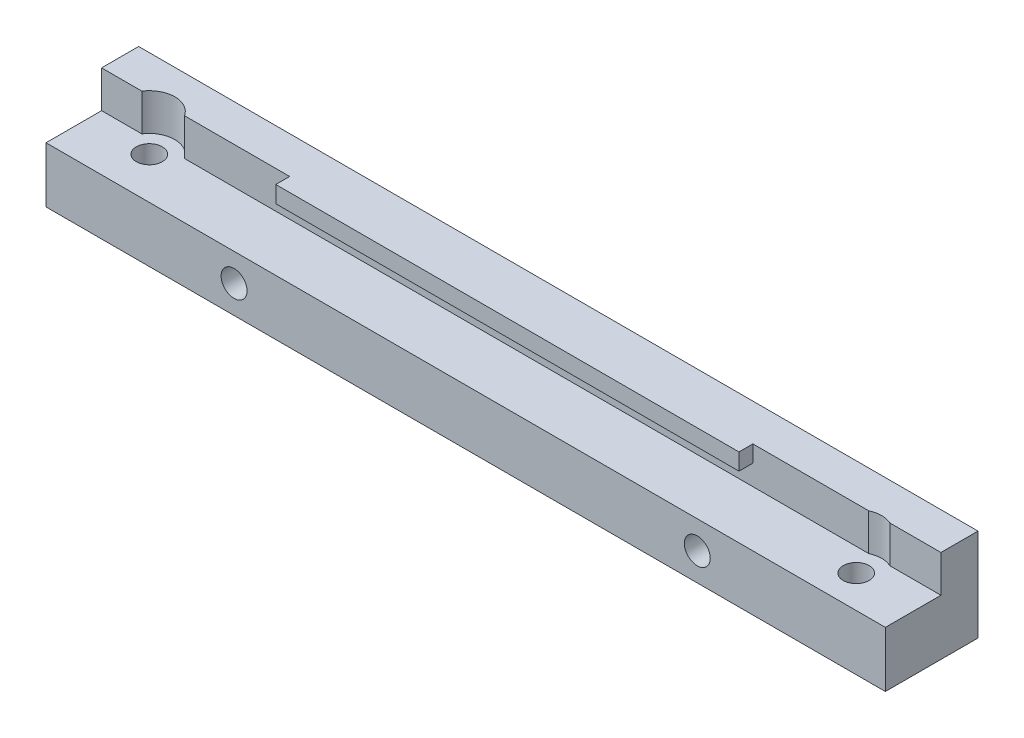
from build123d import *

# Parameters (mm, degrees)
ESQUISSE1_W             = 90.6
ESQUISSE1_H             = 10
BOSS_EXTRU_1_DEPTH      = 10
ESQUISSE2_W             = 90.6
ESQUISSE2_H             = 4
ENL_V_MAT_EXTRU_1_DEPTH = 6
ESQUISSE3_R             = 1.4
ENL_V_MAT_EXTRU_2_DEPTH = 6
ESQUISSE4_W             = 50
ESQUISSE4_H             = 1.8
BOSS_EXTRU_2_DEPTH      = 1.5
ESQUISSE5_R             = 2.75
ENL_V_MAT_EXTRU_3_DEPTH = 4
ESQUISSE6_R             = 1.4
ENL_V_MAT_EXTRU_4_DEPTH = 11


with BuildPart() as part:
    # Esquisse1 → Boss.-Extru.1 (new body)
    with BuildSketch(Plane.XY):
        with Locations((45.3, 5)):
            Rectangle(ESQUISSE1_W, ESQUISSE1_H)
    extrude(amount=BOSS_EXTRU_1_DEPTH)

    # Esquisse2 → Enlèv. mat.-Extru.1 (cut)
    with BuildSketch(Plane.XY.offset(10)):
        with Locations((45.3, 8)):
            Rectangle(ESQUISSE2_W, ESQUISSE2_H)
    extrude(amount=-ENL_V_MAT_EXTRU_1_DEPTH, mode=Mode.SUBTRACT)

    # Esquisse3 → Enlèv. mat.-Extru.2 (cut)
    with BuildSketch(Plane(origin=(0, 6, 0), x_dir=(1, 0, 0), z_dir=(0, 1, 0))):
        with Locations((6.65, -5.5)):
            Circle(ESQUISSE3_R)
        with Locations((83.95, -6.5)):
            Circle(ESQUISSE3_R)
    extrude(amount=-ENL_V_MAT_EXTRU_2_DEPTH, mode=Mode.SUBTRACT)

    # Esquisse4 → Boss.-Extru.2 (add)
    with BuildSketch(Plane.XY.offset(4)):
        with Locations((45.3, 9.1)):
            Rectangle(ESQUISSE4_W, ESQUISSE4_H)
    extrude(amount=BOSS_EXTRU_2_DEPTH)

    # Esquisse5 → Enlèv. mat.-Extru.3 (cut)
    with BuildSketch(Plane(origin=(0, 10, 0), x_dir=(1, 0, 0), z_dir=(0, 1, 0))):
        with Locations((6.65, -5.5)):
            Circle(ESQUISSE5_R)
        with Locations((83.95, -6.5)):
            Circle(ESQUISSE5_R)
    extrude(amount=-ENL_V_MAT_EXTRU_3_DEPTH, mode=Mode.SUBTRACT)

    # Esquisse6 → Enlèv. mat.-Extru.4 (cut, through all)
    with BuildSketch(Plane.XY.offset(10)):
        with Locations((20.3, 3)):
            Circle(ESQUISSE6_R)
        with Locations((70.3, 3)):
            Circle(ESQUISSE6_R)
    extrude(amount=-ENL_V_MAT_EXTRU_4_DEPTH, mode=Mode.SUBTRACT)


solid = part.part
